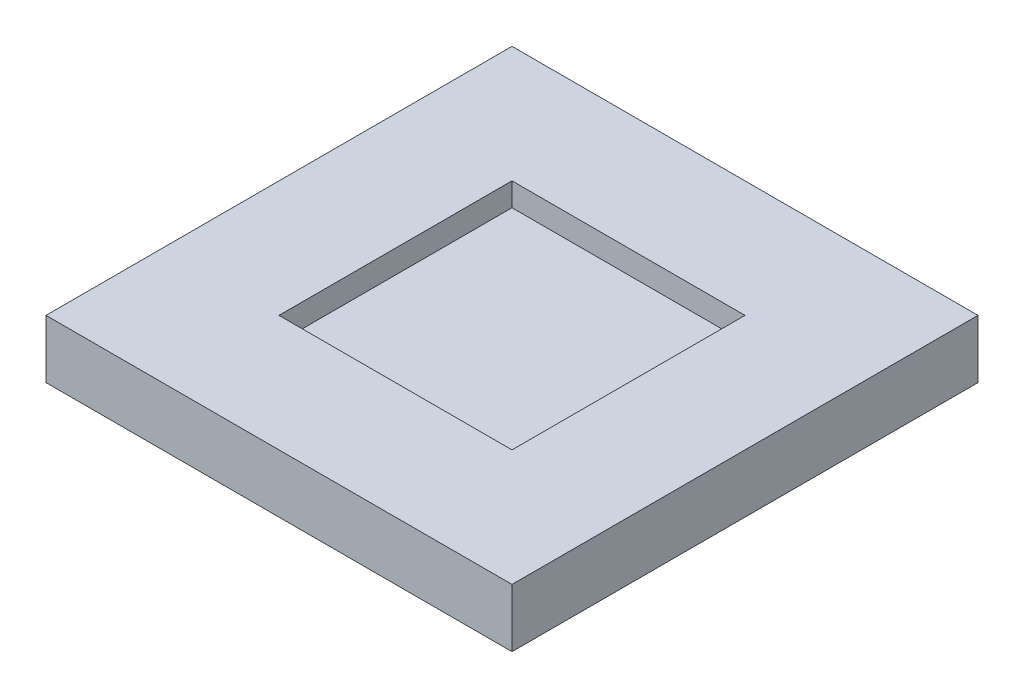
from build123d import *

# Parameters (mm, degrees)
SKETCH1_W           = 101.6
SKETCH1_H           = 101.6
BOSS_EXTRUDE1_DEPTH = 12.7
SKETCH2_W           = 50.8
SKETCH2_H           = 50.8
CUT_EXTRUDE1_DEPTH  = 5.08


with BuildPart() as part:
    # Sketch1 → Boss-Extrude1 (new body)
    with BuildSketch(Plane(origin=(0, 0, 0), x_dir=(1, 0, 0), z_dir=(0, 1, 0))):
        Rectangle(SKETCH1_W, SKETCH1_H)
    extrude(amount=BOSS_EXTRUDE1_DEPTH)

    # Sketch2 → Cut-Extrude1 (cut)
    with BuildSketch(Plane(origin=(0, 12.7, 0), x_dir=(1, 0, 0), z_dir=(0, 1, 0))):
        Rectangle(SKETCH2_W, SKETCH2_H)
    extrude(amount=-CUT_EXTRUDE1_DEPTH, mode=Mode.SUBTRACT)


solid = part.part
